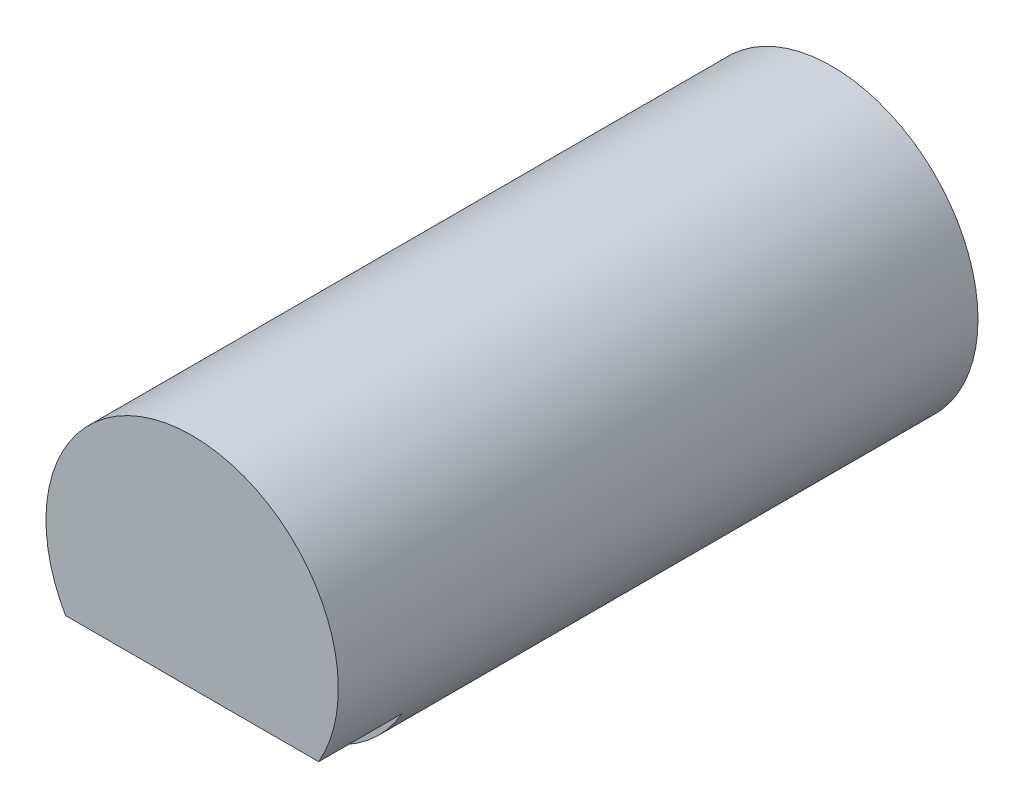
from build123d import *

# Parameters (mm, degrees)
SKETCH1_R           = 5.926666667
BOSS_EXTRUDE1_DEPTH = 22.552
BOSS_EXTRUDE2_DEPTH = 3.386666667


with BuildPart() as part:
    # Sketch1 → Boss-Extrude1 (new body)
    with BuildSketch(Plane.XY):
        with Locations((-166.361835023, 44.902323519)):
            Circle(SKETCH1_R)
    extrude(amount=BOSS_EXTRUDE1_DEPTH)

    # Sketch2 → Boss-Extrude2 (add)
    with BuildSketch(Plane.XY.offset(22.552)):
        with BuildLine():
            Line((-171.494478916, 41.938990186), (-166.361835023, 41.938990186))
            Line((-166.361835023, 41.938990186), (-161.22919113, 41.938990186))
            ThreePointArc((-161.22919113, 41.938990186), (-160.637114626, 43.368389312), (-160.435168356, 44.902323519))
            ThreePointArc((-160.435168356, 44.902323519), (-167.89576923, 50.627043916), (-171.494478916, 41.938990186))
        make_face()
    extrude(amount=BOSS_EXTRUDE2_DEPTH)


solid = part.part
